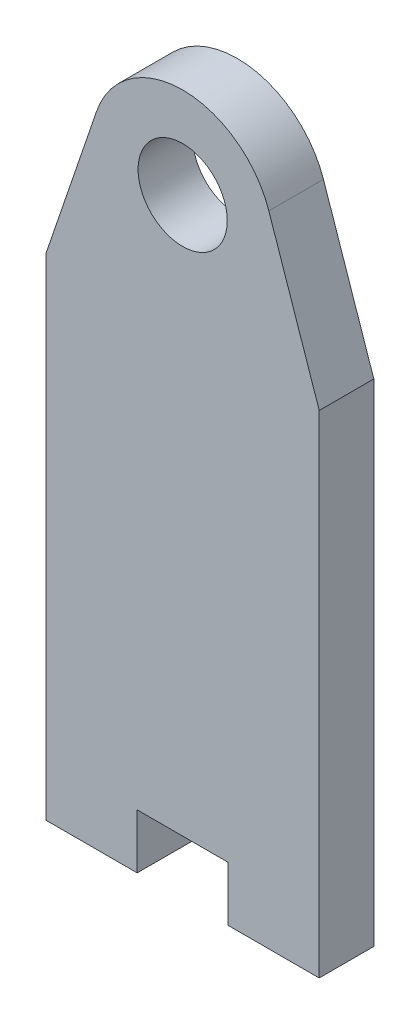
from build123d import *

# Parameters (mm, degrees)
MODEL_R                 = 2.45
SALIENTE_EXTRUIR1_DEPTH = 3


with BuildPart() as part:
    # Model → Saliente-Extruir1 (new body)
    with BuildSketch(Plane.XY):
        with BuildLine():
            Line((21.405501636, 24.45), (21.405501636, -2.55))
            Line((21.405501636, -2.55), (26.405501636, -2.55))
            Line((26.405501636, -2.55), (26.405501636, 0.45))
            Line((26.405501636, 0.45), (31.405501636, 0.45))
            Line((31.405501636, 0.45), (31.405501636, -2.55))
            Line((31.405501636, -2.55), (36.405501636, -2.55))
            Line((36.405501636, -2.55), (36.405501636, 24.45))
            Line((36.405501636, 24.45), (33.6377804, 32.564167804))
            ThreePointArc((33.6377804, 32.564167804), (28.905501636, 35.95), (24.173222872, 32.564167804))
            Line((24.173222872, 32.564167804), (21.405501636, 24.45))
        make_face()
        with Locations((28.904084013, 30.95)):
            Circle(MODEL_R, mode=Mode.SUBTRACT)
    extrude(amount=SALIENTE_EXTRUIR1_DEPTH)


solid = part.part
